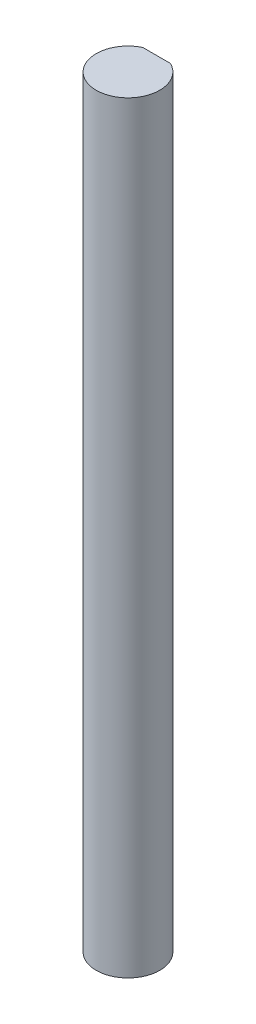
from build123d import *

# Parameters (mm, degrees)
BOSS_EXTRUDE1_DEPTH = 60


with BuildPart() as part:
    # Sketch1 → Boss-Extrude1 (new body)
    with BuildSketch(Plane(origin=(0, 0, 0), x_dir=(1, 0, 0), z_dir=(0, 1, 0))):
        with BuildLine():
            Line((-1.089724736, 2.25), (1.089724736, 2.25))
            ThreePointArc((1.089724736, 2.25), (0, -2.5), (-1.089724736, 2.25))
        make_face()
    extrude(amount=BOSS_EXTRUDE1_DEPTH)


solid = part.part
